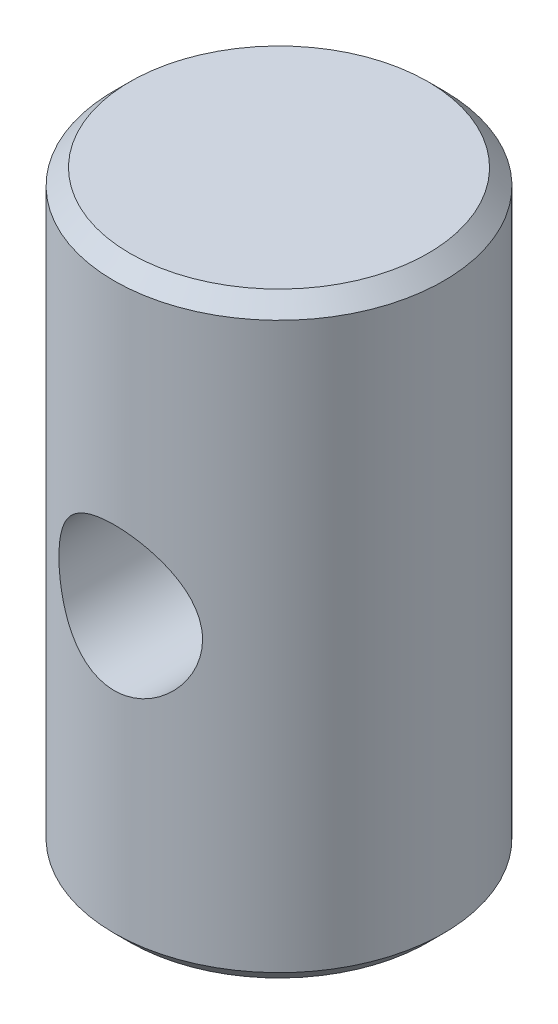
from build123d import *

# Parameters (mm, degrees)
SKETCH1_R                           = 3.9624
BOSS_EXTRUDE1_DEPTH                 = 14.351
CHAMFER1_SIZE                       = 0.381
F_9_64_0_14063_DIAMETER_HOLE3_D     = 3.4544
F_9_64_0_14063_DIAMETER_HOLE3_DEPTH = 6.35
F_9_64_0_14063_DIAMETER_HOLE3_TIP   = 1.037806461


with BuildPart() as part:
    # Sketch1 → Boss-Extrude1 (new body)
    with BuildSketch(Plane(origin=(0, 0, 0), x_dir=(1, 0, 0), z_dir=(0, 1, 0))):
        Circle(SKETCH1_R)
    extrude(amount=BOSS_EXTRUDE1_DEPTH)

    # Chamfer1
    chamfer1_edges = [part.edges().sort_by_distance(p)[0] for p in [
        (-3.9624, 0, 0),
        (-3.9624, 14.351, 0),
    ]]
    chamfer(chamfer1_edges, length=CHAMFER1_SIZE)

    # 9/64 (0.14063) Diameter Hole3
    with Locations(Plane.XY.offset(3.96875)):
        with Locations((0, 7.1628)):
            Hole(F_9_64_0_14063_DIAMETER_HOLE3_D / 2, depth=F_9_64_0_14063_DIAMETER_HOLE3_DEPTH)
            with Locations((0, 0, -(F_9_64_0_14063_DIAMETER_HOLE3_DEPTH + F_9_64_0_14063_DIAMETER_HOLE3_TIP / 2))):  # 118° drill point
                Cone(0, F_9_64_0_14063_DIAMETER_HOLE3_D / 2, F_9_64_0_14063_DIAMETER_HOLE3_TIP, mode=Mode.SUBTRACT)


solid = part.part
